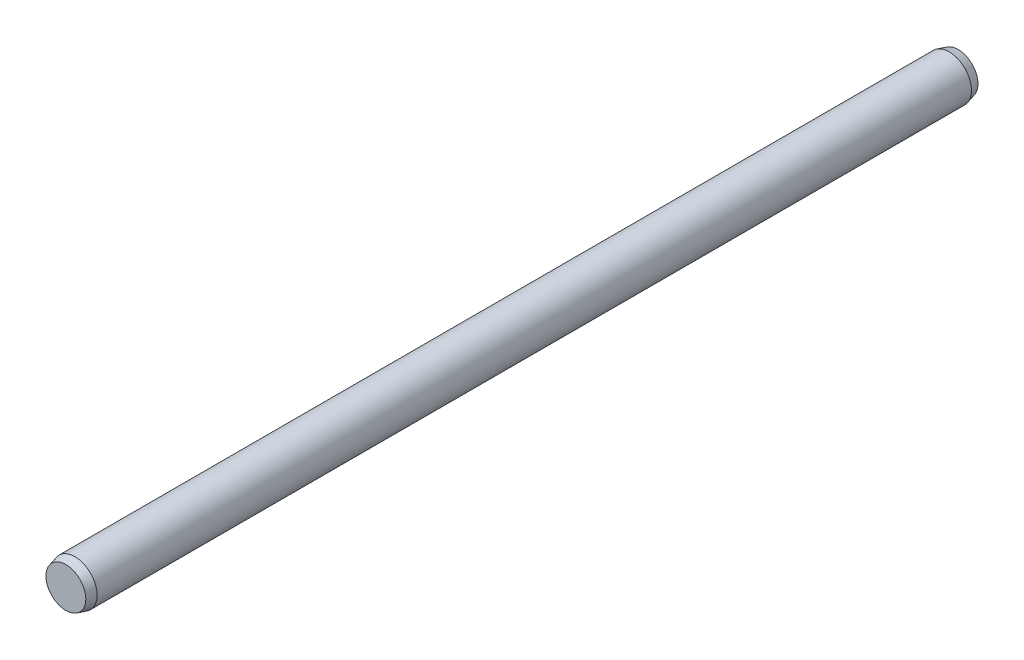
from build123d import *


with BuildPart() as part:
    # Sketch3 → Revolve1 (revolve)
    with BuildSketch(Plane(origin=(0, 0, 0), x_dir=(0, 0, -1), z_dir=(1, 0, 0))):
        Polygon((-10, 0), (-10, 0.446410162), (-9.8, 0.5), (9.8, 0.5), (10, 0.446410162), (10, 0), align=None)
    revolve(axis=Axis((0, 0, 10), (0, 0, -1)))


solid = part.part
